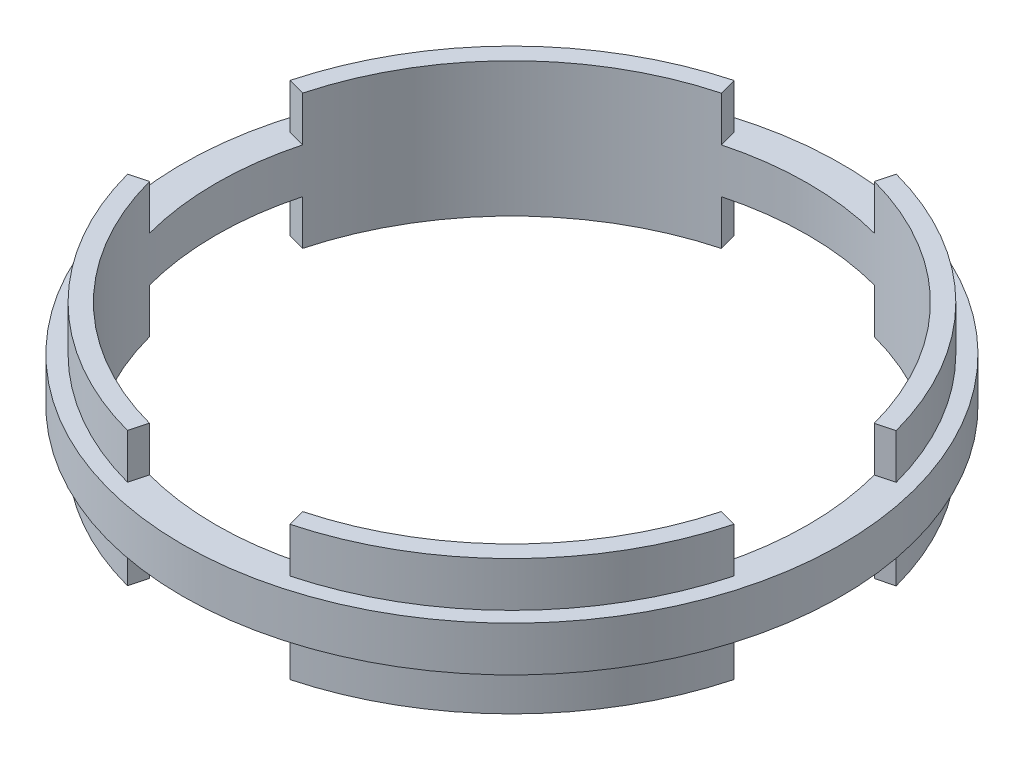
from build123d import *
from build123d.topology import SkipClean

# Parameters (mm, degrees)
SKETCH1_R           = 93.345
SKETCH1_R_2         = 83.82
BOSS_EXTRUDE1_DEPTH = 6.35
SKETCH2_R           = 88.9
SKETCH2_R_2         = 83.82
BOSS_EXTRUDE2_DEPTH = 19.05
CUT_EXTRUDE1_DEPTH  = 38.1
CIRPATTERN1_COUNT   = 4
SKETCH4_R           = 88.9
SKETCH4_R_2         = 83.82
BOSS_EXTRUDE3_DEPTH = 6.35


with BuildPart() as part:
    # Sketch1 → Boss-Extrude1 (new, symmetric)
    with BuildSketch(Plane(origin=(0, 0, 0), x_dir=(1, 0, 0), z_dir=(0, 1, 0))):
        with Locations(Location((0, 0, 0), (0, 0, 270))):
            Circle(SKETCH1_R)
        with Locations(Location((0, 0, 0), (0, 0, 270))):
            Circle(SKETCH1_R_2, mode=Mode.SUBTRACT)
    extrude(amount=BOSS_EXTRUDE1_DEPTH, both=True)

    # Sketch2 → Boss-Extrude2 (add, symmetric)
    with BuildSketch(Plane(origin=(0, 0, 0), x_dir=(1, 0, 0), z_dir=(0, 1, 0))):
        with Locations(Location((0, 0, 0), (0, 0, 90))):
            Circle(SKETCH2_R)
        with Locations(Location((0, 0, 0), (0, 0, 270))):
            Circle(SKETCH2_R_2, mode=Mode.SUBTRACT)
    extrude(amount=BOSS_EXTRUDE2_DEPTH, both=True)

    # Sketch3 → Cut-Extrude1 (cut, symmetric)
    with BuildSketch(Plane(origin=(0, 0, 0), x_dir=(1, 0, 0), z_dir=(0, 1, 0))):
        with BuildLine():
            Line((0, 0), (-22.96498538, 85.882591056))
            ThreePointArc((-22.96498538, 85.882591056), (0.022788865, 88.899997079), (23.00901311, 85.870805957))
            Line((23.00901311, 85.870805957), (0, 0))
        make_face()
    cut_extrude1 = extrude(amount=CUT_EXTRUDE1_DEPTH, both=True, mode=Mode.SUBTRACT)

    # CirPattern1: Cut-Extrude1 ×4 about axis
    cirpattern1_axis = Axis((0, 19.05, 0), (0, -1, 0))
    for i in range(1, CIRPATTERN1_COUNT):
        add(cut_extrude1.rotate(cirpattern1_axis, i * 360 / CIRPATTERN1_COUNT), mode=Mode.SUBTRACT)

    # Sketch4 → Boss-Extrude3 (add, symmetric)
    with SkipClean():  # the faces are left unmerged after this step: merging them gives an invalid solid
        with BuildSketch(Plane(origin=(0, 0, 0), x_dir=(1, 0, 0), z_dir=(0, 1, 0))):
            Circle(SKETCH4_R)
            with Locations(Location((0, 0, 0), (0, 0, 104.970625291))):
                Circle(SKETCH4_R_2, mode=Mode.SUBTRACT)
        extrude(amount=BOSS_EXTRUDE3_DEPTH, both=True)


solid = part.part
